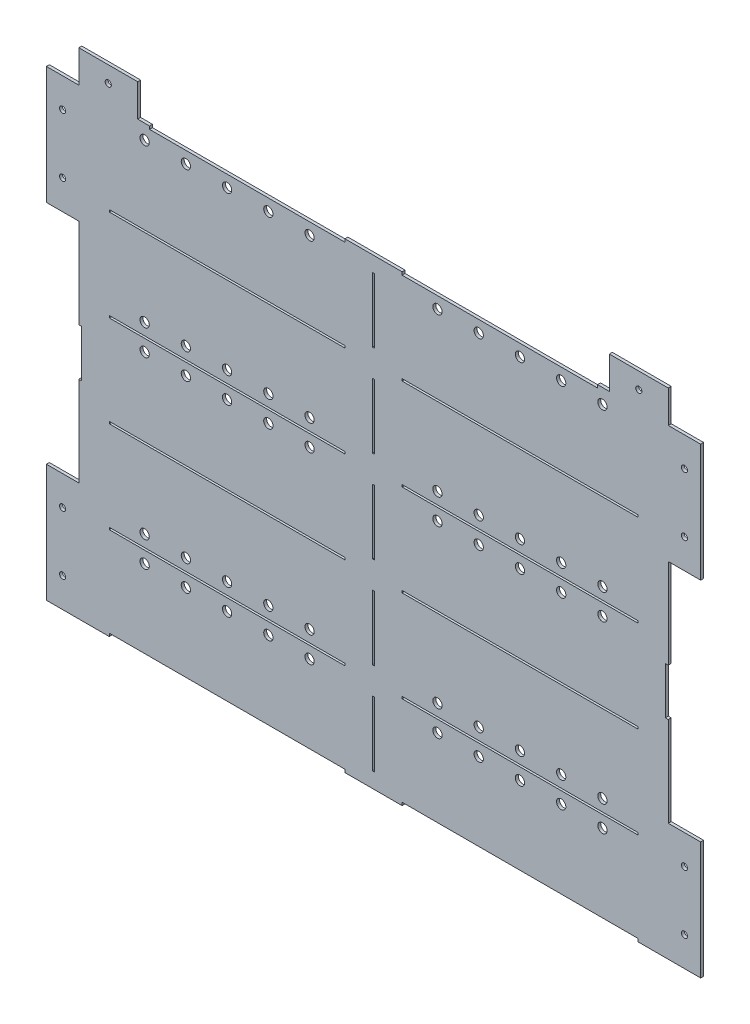
from build123d import *

# Parameters (mm, degrees)
MASTER_SKETCH_W            = 635.3556
MASTER_SKETCH_H            = 498.348
BOSS_EXTRUDE1_DEPTH        = 3.175
SKETCH2_W                  = 34.925
SKETCH2_H                  = 127
BOSS_EXTRUDE2_DEPTH        = 3.175
M6_CLEARANCE_HOLE1_D       = 6.6
MIRROR7_COPY_1_SKETCH_W    = 34.925
MIRROR7_COPY_1_SKETCH_H    = 127
MIRROR7_COPY_1_DEPTH       = 3.175
MIRROR7_COPY_2_D           = 6.6
SKETCH5_W                  = 2.286
SKETCH5_H                  = 69.85
CUT_EXTRUDE1_DEPTH         = 4.175
LPATTERN1_COUNT            = 5
LPATTERN1_PITCH            = 98.8568
SKETCH7_W                  = 254
SKETCH7_H                  = 2.286
CUT_EXTRUDE3_DEPTH         = 4.175
LPATTERN2_COUNT            = 4
LPATTERN2_PITCH            = 98.8568
MIRROR4_COPY_1_SKETCH_W    = 254
MIRROR4_COPY_1_SKETCH_H    = 2.286
MIRROR4_COPY_1_DEPTH       = 4.175
MIRROR4_COPY_2_SKETCH_W    = 254
MIRROR4_COPY_2_SKETCH_H    = 2.286
MIRROR4_COPY_2_DEPTH       = 4.175
MIRROR4_COPY_3_SKETCH_W    = 254
MIRROR4_COPY_3_SKETCH_H    = 2.286
MIRROR4_COPY_3_DEPTH       = 4.175
SKETCH10_W                 = 63.5
SKETCH10_H                 = 34.925
SKETCH10_R                 = 3
BOSS_EXTRUDE3_DEPTH        = 3.175
M6_CLEARANCE_HOLE2_D       = 6.6
SKETCH6_W                  = 254
SKETCH6_H                  = 3.175
SKETCH6_W_2                = 210.6549
CUT_EXTRUDE2_DEPTH         = 4.175
SKETCH15_W                 = 6.35
SKETCH15_H                 = 50.8
CUT_EXTRUDE4_DEPTH         = 4.175
SKETCH16_R                 = 5
CUT_EXTRUDE5_DEPTH         = 4.175
LPATTERN3_COUNT            = 3
LPATTERN3_PITCH            = 44.45
LPATTERN3_COL_COUNT        = 3
LPATTERN3_COL_PITCH        = 44.45
MIRROR9_COPY_1_SKETCH_R    = 5
MIRROR9_COPY_1_DEPTH       = 4.175
MIRROR9_COPY_2_SKETCH_R    = 5
MIRROR9_COPY_2_DEPTH       = 4.175
MIRROR9_COPY_3_SKETCH_R    = 5
MIRROR9_COPY_3_DEPTH       = 4.175
MIRROR9_COPY_4_SKETCH_R    = 5
MIRROR9_COPY_4_DEPTH       = 4.175
MIRROR10_COPY_1_SKETCH_R   = 5
MIRROR10_COPY_1_DEPTH      = 4.175
MIRROR10_COPY_2_SKETCH_R   = 5
MIRROR10_COPY_2_DEPTH      = 4.175
MIRROR10_COPY_3_SKETCH_R   = 5
MIRROR10_COPY_3_DEPTH      = 4.175
MIRROR10_COPY_4_SKETCH_R   = 5
MIRROR10_COPY_4_DEPTH      = 4.175
MIRROR10_COPY_5_SKETCH_R   = 5
MIRROR10_COPY_5_DEPTH      = 4.175
MIRROR10_COPY_6_SKETCH_R   = 5
MIRROR10_COPY_6_DEPTH      = 4.175
MIRROR10_COPY_7_SKETCH_R   = 5
MIRROR10_COPY_7_DEPTH      = 4.175
MIRROR10_COPY_8_SKETCH_R   = 5
MIRROR10_COPY_8_DEPTH      = 4.175
MIRROR10_COPY_9_SKETCH_R   = 5
MIRROR10_COPY_9_DEPTH      = 4.175
LPATTERN4_COUNT            = 2
LPATTERN4_PITCH            = 395.4272
LPATTERN4_COPY_1_SKETCH_R  = 5
LPATTERN4_COPY_1_DEPTH     = 4.175
LPATTERN4_COPY_2_SKETCH_R  = 5
LPATTERN4_COPY_2_DEPTH     = 4.175
LPATTERN4_COPY_3_SKETCH_R  = 5
LPATTERN4_COPY_3_DEPTH     = 4.175
LPATTERN4_COPY_4_SKETCH_R  = 5
LPATTERN4_COPY_4_DEPTH     = 4.175
LPATTERN4_COPY_5_SKETCH_R  = 5
LPATTERN4_COPY_5_DEPTH     = 4.175
LPATTERN4_COPY_6_SKETCH_R  = 5
LPATTERN4_COPY_6_DEPTH     = 4.175
LPATTERN4_COPY_7_SKETCH_R  = 5
LPATTERN4_COPY_7_DEPTH     = 4.175
LPATTERN4_COPY_8_SKETCH_R  = 5
LPATTERN4_COPY_8_DEPTH     = 4.175
LPATTERN4_COPY_9_SKETCH_R  = 5
LPATTERN4_COPY_9_DEPTH     = 4.175
LPATTERN6_COUNT            = 2
LPATTERN6_PITCH            = 197.7136
LPATTERN6_COPY_1_SKETCH_R  = 5
LPATTERN6_COPY_1_DEPTH     = 4.175
LPATTERN6_COPY_2_SKETCH_R  = 5
LPATTERN6_COPY_2_DEPTH     = 4.175
LPATTERN6_COPY_3_SKETCH_R  = 5
LPATTERN6_COPY_3_DEPTH     = 4.175
LPATTERN6_COPY_4_SKETCH_R  = 5
LPATTERN6_COPY_4_DEPTH     = 4.175
LPATTERN6_COPY_5_SKETCH_R  = 5
LPATTERN6_COPY_5_DEPTH     = 4.175
LPATTERN6_COPY_6_SKETCH_R  = 5
LPATTERN6_COPY_6_DEPTH     = 4.175
LPATTERN6_COPY_7_SKETCH_R  = 5
LPATTERN6_COPY_7_DEPTH     = 4.175
LPATTERN6_COPY_8_SKETCH_R  = 5
LPATTERN6_COPY_8_DEPTH     = 4.175
LPATTERN6_COPY_9_SKETCH_R  = 5
LPATTERN6_COPY_9_DEPTH     = 4.175
LPATTERN6_COPY_10_SKETCH_R = 5
LPATTERN6_COPY_10_DEPTH    = 4.175
LPATTERN6_COPY_11_SKETCH_R = 5
LPATTERN6_COPY_11_DEPTH    = 4.175
LPATTERN6_COPY_12_SKETCH_R = 5
LPATTERN6_COPY_12_DEPTH    = 4.175
LPATTERN6_COPY_13_SKETCH_R = 5
LPATTERN6_COPY_13_DEPTH    = 4.175
LPATTERN6_COPY_14_SKETCH_R = 5
LPATTERN6_COPY_14_DEPTH    = 4.175
LPATTERN6_COPY_15_SKETCH_R = 5
LPATTERN6_COPY_15_DEPTH    = 4.175
LPATTERN6_COPY_16_SKETCH_R = 5
LPATTERN6_COPY_16_DEPTH    = 4.175
LPATTERN6_COPY_17_SKETCH_R = 5
LPATTERN6_COPY_17_DEPTH    = 4.175
LPATTERN6_COPY_18_SKETCH_R = 5
LPATTERN6_COPY_18_DEPTH    = 4.175
LPATTERN6_COPY_19_SKETCH_R = 5
LPATTERN6_COPY_19_DEPTH    = 4.175


with BuildPart() as part:
    # Master Sketch → Boss-Extrude1 (new body)
    with BuildSketch(Plane.XY):
        Rectangle(MASTER_SKETCH_W, MASTER_SKETCH_H)
    extrude(amount=BOSS_EXTRUDE1_DEPTH)

    # Sketch2 → Boss-Extrude2 (add)
    with BuildSketch(Plane.XY.offset(3.175)):
        with Locations((-335.1403, -185.674)):
            Rectangle(SKETCH2_W, SKETCH2_H)
    boss_extrude2 = extrude(amount=-BOSS_EXTRUDE2_DEPTH)

    # M6 Clearance Hole1 (through all)
    with Locations(Plane.XY.offset(3.175)):
        with Locations((-335.1403, -217.424), (-335.1403, -153.924)):
            m6_clearance_hole1 = Hole(M6_CLEARANCE_HOLE1_D / 2)

    # Mirror1: Boss-Extrude2, M6 Clearance Hole1 across plane
    add(boss_extrude2.mirror(Plane(origin=(0, 0, 0), x_dir=(0, 0, 1), z_dir=(1, 0, 0))))
    add(m6_clearance_hole1.mirror(Plane(origin=(0, 0, 0), x_dir=(0, 0, 1), z_dir=(1, 0, 0))), mode=Mode.SUBTRACT)

    # Mirror7: Boss-Extrude2, M6 Clearance Hole1 across plane
    add(boss_extrude2.mirror(Plane.ZX))
    add(m6_clearance_hole1.mirror(Plane.ZX), mode=Mode.SUBTRACT)

    # Mirror7 copy 1 sketch → Mirror7 copy 1 (add)
    with BuildSketch(Plane(origin=(0, 0, 3.175), x_dir=(-1, 0, 0), z_dir=(0, 0, 1))):
        with Locations((-335.1403, -185.674)):
            Rectangle(MIRROR7_COPY_1_SKETCH_W, MIRROR7_COPY_1_SKETCH_H)
    extrude(amount=-MIRROR7_COPY_1_DEPTH)

    # Mirror7 copy 2 (through all)
    with Locations(Plane(origin=(0, 0, 3.175), x_dir=(-1, 0, 0), z_dir=(0, 0, 1))):
        with Locations((-335.1403, -217.424), (-335.1403, -153.924)):
            Hole(MIRROR7_COPY_2_D / 2)

    # Sketch5 → Cut-Extrude1 (cut, through all)
    with BuildSketch(Plane.XY.offset(3.175)):
        with Locations((0, 197.7136)):
            Rectangle(SKETCH5_W, SKETCH5_H)
    cut_extrude1 = extrude(amount=-CUT_EXTRUDE1_DEPTH, mode=Mode.SUBTRACT)

    # LPattern1: Cut-Extrude1 ×5
    with Locations(*[(0, -i * LPATTERN1_PITCH, 0) for i in range(1, LPATTERN1_COUNT)]):
        add(cut_extrude1, mode=Mode.SUBTRACT)

    # Sketch7 → Cut-Extrude3 (cut, through all)
    with BuildSketch(Plane.XY.offset(3.175)):
        with Locations((-157.8229, 148.2852)):
            Rectangle(SKETCH7_W, SKETCH7_H)
    cut_extrude3 = extrude(amount=-CUT_EXTRUDE3_DEPTH, mode=Mode.SUBTRACT)

    # LPattern2: Cut-Extrude3 ×4
    with Locations(*[(0, -i * LPATTERN2_PITCH, 0) for i in range(1, LPATTERN2_COUNT)]):
        add(cut_extrude3, mode=Mode.SUBTRACT)

    # Mirror4: Cut-Extrude3 across plane
    add(cut_extrude3.mirror(Plane(origin=(0, 0, 0), x_dir=(0, 0, 1), z_dir=(1, 0, 0))), mode=Mode.SUBTRACT)

    # Mirror4 copy 1 sketch → Mirror4 copy 1 (cut, through all)
    with BuildSketch(Plane(origin=(0, -98.8568, 3.175), x_dir=(-1, 0, 0), z_dir=(0, 0, 1))):
        with Locations((-157.8229, -148.2852)):
            Rectangle(MIRROR4_COPY_1_SKETCH_W, MIRROR4_COPY_1_SKETCH_H)
    extrude(amount=-MIRROR4_COPY_1_DEPTH, mode=Mode.SUBTRACT)

    # Mirror4 copy 2 sketch → Mirror4 copy 2 (cut, through all)
    with BuildSketch(Plane(origin=(0, -197.7136, 3.175), x_dir=(-1, 0, 0), z_dir=(0, 0, 1))):
        with Locations((-157.8229, -148.2852)):
            Rectangle(MIRROR4_COPY_2_SKETCH_W, MIRROR4_COPY_2_SKETCH_H)
    extrude(amount=-MIRROR4_COPY_2_DEPTH, mode=Mode.SUBTRACT)

    # Mirror4 copy 3 sketch → Mirror4 copy 3 (cut, through all)
    with BuildSketch(Plane(origin=(0, -296.5704, 3.175), x_dir=(-1, 0, 0), z_dir=(0, 0, 1))):
        with Locations((-157.8229, -148.2852)):
            Rectangle(MIRROR4_COPY_3_SKETCH_W, MIRROR4_COPY_3_SKETCH_H)
    extrude(amount=-MIRROR4_COPY_3_DEPTH, mode=Mode.SUBTRACT)

    # Sketch10 → Boss-Extrude3 (add)
    with BuildSketch(Plane.XY.offset(3.175)):
        with Locations((-285.9278, 266.6365)):
            Rectangle(SKETCH10_W, SKETCH10_H)
        with Locations((-285.9278, 266.6365)):
            Circle(SKETCH10_R, mode=Mode.SUBTRACT)
    boss_extrude3 = extrude(amount=-BOSS_EXTRUDE3_DEPTH)

    # M6 Clearance Hole2 (through all)
    with Locations(Plane.XY.offset(3.175)):
        with Locations((-285.9278, 266.6365)):
            m6_clearance_hole2 = Hole(M6_CLEARANCE_HOLE2_D / 2)

    # Mirror6: Boss-Extrude3, M6 Clearance Hole2 across plane
    add(boss_extrude3.mirror(Plane(origin=(0, 0, 0), x_dir=(0, 0, 1), z_dir=(1, 0, 0))))
    add(m6_clearance_hole2.mirror(Plane(origin=(0, 0, 0), x_dir=(0, 0, 1), z_dir=(1, 0, 0))), mode=Mode.SUBTRACT)

    # Sketch6 → Cut-Extrude2 (cut, through all)
    with BuildSketch(Plane.XY.offset(3.175)):
        with Locations((-157.8229, -247.5865)):
            Rectangle(SKETCH6_W, SKETCH6_H)
        with Locations((157.8229, -247.5865)):
            Rectangle(SKETCH6_W, SKETCH6_H)
        with Locations((-136.15035, 247.5865)):
            Rectangle(SKETCH6_W_2, SKETCH6_H)
        with Locations((136.15035, 247.5865)):
            Rectangle(SKETCH6_W_2, SKETCH6_H)
    extrude(amount=-CUT_EXTRUDE2_DEPTH, mode=Mode.SUBTRACT)

    # Sketch15 → Cut-Extrude4 (cut, through all)
    with BuildSketch(Plane(origin=(0, 0, 0), x_dir=(-1, 0, 0), z_dir=(0, 0, -1))):
        with Locations((317.6778, 0)):
            Rectangle(SKETCH15_W, SKETCH15_H)
    cut_extrude4 = extrude(amount=-CUT_EXTRUDE4_DEPTH, mode=Mode.SUBTRACT)

    # Mirror8: Cut-Extrude4 across plane
    add(cut_extrude4.mirror(Plane(origin=(0, 0, 0), x_dir=(0, 0, 1), z_dir=(1, 0, 0))), mode=Mode.SUBTRACT)

    # Sketch16 → Cut-Extrude5 (cut, through all)
    with BuildSketch(Plane(origin=(0, 0, 0), x_dir=(-1, 0, 0), z_dir=(0, 0, -1))):
        with Locations((-157.8229, -162.1282)):
            Circle(SKETCH16_R)
    cut_extrude5 = extrude(amount=-CUT_EXTRUDE5_DEPTH, mode=Mode.SUBTRACT)

    # LPattern3: Cut-Extrude5 ×3
    with Locations(*[(i * LPATTERN3_PITCH, 0, 0) for i in range(1, LPATTERN3_COUNT)]):
        add(cut_extrude5, mode=Mode.SUBTRACT)

    # LPattern3 col: Cut-Extrude5 ×3
    with Locations(*[(-i * LPATTERN3_COL_PITCH, 0, 0) for i in range(1, LPATTERN3_COL_COUNT)]):
        add(cut_extrude5, mode=Mode.SUBTRACT)

    # Mirror9: Cut-Extrude5 across plane
    add(cut_extrude5.mirror(Plane(origin=(0, 0, 0), x_dir=(0, 0, 1), z_dir=(1, 0, 0))), mode=Mode.SUBTRACT)

    # Mirror9 copy 1 sketch → Mirror9 copy 1 (cut, through all)
    with BuildSketch(Plane(origin=(-44.45, 0, 0), x_dir=(1, 0, 0), z_dir=(0, 0, -1))):
        with Locations((-157.8229, 162.1282)):
            Circle(MIRROR9_COPY_1_SKETCH_R)
    extrude(amount=-MIRROR9_COPY_1_DEPTH, mode=Mode.SUBTRACT)

    # Mirror9 copy 2 sketch → Mirror9 copy 2 (cut, through all)
    with BuildSketch(Plane(origin=(-88.9, 0, 0), x_dir=(1, 0, 0), z_dir=(0, 0, -1))):
        with Locations((-157.8229, 162.1282)):
            Circle(MIRROR9_COPY_2_SKETCH_R)
    extrude(amount=-MIRROR9_COPY_2_DEPTH, mode=Mode.SUBTRACT)

    # Mirror9 copy 3 sketch → Mirror9 copy 3 (cut, through all)
    with BuildSketch(Plane(origin=(44.45, 0, 0), x_dir=(1, 0, 0), z_dir=(0, 0, -1))):
        with Locations((-157.8229, 162.1282)):
            Circle(MIRROR9_COPY_3_SKETCH_R)
    extrude(amount=-MIRROR9_COPY_3_DEPTH, mode=Mode.SUBTRACT)

    # Mirror9 copy 4 sketch → Mirror9 copy 4 (cut, through all)
    with BuildSketch(Plane(origin=(88.9, 0, 0), x_dir=(1, 0, 0), z_dir=(0, 0, -1))):
        with Locations((-157.8229, 162.1282)):
            Circle(MIRROR9_COPY_4_SKETCH_R)
    extrude(amount=-MIRROR9_COPY_4_DEPTH, mode=Mode.SUBTRACT)

    # Mirror10: Cut-Extrude5 across plane
    add(cut_extrude5.mirror(Plane.ZX.offset(-148.2852)), mode=Mode.SUBTRACT)

    # Mirror10 copy 1 sketch → Mirror10 copy 1 (cut, through all)
    with BuildSketch(Plane(origin=(0, -296.5704, 0), x_dir=(1, 0, 0), z_dir=(0, 0, -1))):
        with Locations((-157.8229, -162.1282)):
            Circle(MIRROR10_COPY_1_SKETCH_R)
    extrude(amount=-MIRROR10_COPY_1_DEPTH, mode=Mode.SUBTRACT)

    # Mirror10 copy 2 sketch → Mirror10 copy 2 (cut, through all)
    with BuildSketch(Plane(origin=(-44.45, -296.5704, 0), x_dir=(1, 0, 0), z_dir=(0, 0, -1))):
        with Locations((-157.8229, -162.1282)):
            Circle(MIRROR10_COPY_2_SKETCH_R)
    extrude(amount=-MIRROR10_COPY_2_DEPTH, mode=Mode.SUBTRACT)

    # Mirror10 copy 3 sketch → Mirror10 copy 3 (cut, through all)
    with BuildSketch(Plane(origin=(-88.9, -296.5704, 0), x_dir=(1, 0, 0), z_dir=(0, 0, -1))):
        with Locations((-157.8229, -162.1282)):
            Circle(MIRROR10_COPY_3_SKETCH_R)
    extrude(amount=-MIRROR10_COPY_3_DEPTH, mode=Mode.SUBTRACT)

    # Mirror10 copy 4 sketch → Mirror10 copy 4 (cut, through all)
    with BuildSketch(Plane(origin=(44.45, -296.5704, 0), x_dir=(1, 0, 0), z_dir=(0, 0, -1))):
        with Locations((-157.8229, -162.1282)):
            Circle(MIRROR10_COPY_4_SKETCH_R)
    extrude(amount=-MIRROR10_COPY_4_DEPTH, mode=Mode.SUBTRACT)

    # Mirror10 copy 5 sketch → Mirror10 copy 5 (cut, through all)
    with BuildSketch(Plane(origin=(88.9, -296.5704, 0), x_dir=(1, 0, 0), z_dir=(0, 0, -1))):
        with Locations((-157.8229, -162.1282)):
            Circle(MIRROR10_COPY_5_SKETCH_R)
    extrude(amount=-MIRROR10_COPY_5_DEPTH, mode=Mode.SUBTRACT)

    # Mirror10 copy 6 sketch → Mirror10 copy 6 (cut, through all)
    with BuildSketch(Plane(origin=(44.45, -296.5704, 0), x_dir=(-1, 0, 0), z_dir=(0, 0, -1))):
        with Locations((-157.8229, 162.1282)):
            Circle(MIRROR10_COPY_6_SKETCH_R)
    extrude(amount=-MIRROR10_COPY_6_DEPTH, mode=Mode.SUBTRACT)

    # Mirror10 copy 7 sketch → Mirror10 copy 7 (cut, through all)
    with BuildSketch(Plane(origin=(88.9, -296.5704, 0), x_dir=(-1, 0, 0), z_dir=(0, 0, -1))):
        with Locations((-157.8229, 162.1282)):
            Circle(MIRROR10_COPY_7_SKETCH_R)
    extrude(amount=-MIRROR10_COPY_7_DEPTH, mode=Mode.SUBTRACT)

    # Mirror10 copy 8 sketch → Mirror10 copy 8 (cut, through all)
    with BuildSketch(Plane(origin=(-44.45, -296.5704, 0), x_dir=(-1, 0, 0), z_dir=(0, 0, -1))):
        with Locations((-157.8229, 162.1282)):
            Circle(MIRROR10_COPY_8_SKETCH_R)
    extrude(amount=-MIRROR10_COPY_8_DEPTH, mode=Mode.SUBTRACT)

    # Mirror10 copy 9 sketch → Mirror10 copy 9 (cut, through all)
    with BuildSketch(Plane(origin=(-88.9, -296.5704, 0), x_dir=(-1, 0, 0), z_dir=(0, 0, -1))):
        with Locations((-157.8229, 162.1282)):
            Circle(MIRROR10_COPY_9_SKETCH_R)
    extrude(amount=-MIRROR10_COPY_9_DEPTH, mode=Mode.SUBTRACT)

    # LPattern4: Cut-Extrude5 ×2
    with Locations(*[(0, i * LPATTERN4_PITCH, 0) for i in range(1, LPATTERN4_COUNT)]):
        add(cut_extrude5, mode=Mode.SUBTRACT)

    # LPattern4 copy 1 sketch → LPattern4 copy 1 (cut, through all)
    with BuildSketch(Plane(origin=(44.45, 395.4272, 0), x_dir=(-1, 0, 0), z_dir=(0, 0, -1))):
        with Locations((-157.8229, -162.1282)):
            Circle(LPATTERN4_COPY_1_SKETCH_R)
    extrude(amount=-LPATTERN4_COPY_1_DEPTH, mode=Mode.SUBTRACT)

    # LPattern4 copy 2 sketch → LPattern4 copy 2 (cut, through all)
    with BuildSketch(Plane(origin=(88.9, 395.4272, 0), x_dir=(-1, 0, 0), z_dir=(0, 0, -1))):
        with Locations((-157.8229, -162.1282)):
            Circle(LPATTERN4_COPY_2_SKETCH_R)
    extrude(amount=-LPATTERN4_COPY_2_DEPTH, mode=Mode.SUBTRACT)

    # LPattern4 copy 3 sketch → LPattern4 copy 3 (cut, through all)
    with BuildSketch(Plane(origin=(-44.45, 395.4272, 0), x_dir=(-1, 0, 0), z_dir=(0, 0, -1))):
        with Locations((-157.8229, -162.1282)):
            Circle(LPATTERN4_COPY_3_SKETCH_R)
    extrude(amount=-LPATTERN4_COPY_3_DEPTH, mode=Mode.SUBTRACT)

    # LPattern4 copy 4 sketch → LPattern4 copy 4 (cut, through all)
    with BuildSketch(Plane(origin=(-88.9, 395.4272, 0), x_dir=(-1, 0, 0), z_dir=(0, 0, -1))):
        with Locations((-157.8229, -162.1282)):
            Circle(LPATTERN4_COPY_4_SKETCH_R)
    extrude(amount=-LPATTERN4_COPY_4_DEPTH, mode=Mode.SUBTRACT)

    # LPattern4 copy 5 sketch → LPattern4 copy 5 (cut, through all)
    with BuildSketch(Plane(origin=(0, 395.4272, 0), x_dir=(1, 0, 0), z_dir=(0, 0, -1))):
        with Locations((-157.8229, 162.1282)):
            Circle(LPATTERN4_COPY_5_SKETCH_R)
    extrude(amount=-LPATTERN4_COPY_5_DEPTH, mode=Mode.SUBTRACT)

    # LPattern4 copy 6 sketch → LPattern4 copy 6 (cut, through all)
    with BuildSketch(Plane(origin=(-44.45, 395.4272, 0), x_dir=(1, 0, 0), z_dir=(0, 0, -1))):
        with Locations((-157.8229, 162.1282)):
            Circle(LPATTERN4_COPY_6_SKETCH_R)
    extrude(amount=-LPATTERN4_COPY_6_DEPTH, mode=Mode.SUBTRACT)

    # LPattern4 copy 7 sketch → LPattern4 copy 7 (cut, through all)
    with BuildSketch(Plane(origin=(-88.9, 395.4272, 0), x_dir=(1, 0, 0), z_dir=(0, 0, -1))):
        with Locations((-157.8229, 162.1282)):
            Circle(LPATTERN4_COPY_7_SKETCH_R)
    extrude(amount=-LPATTERN4_COPY_7_DEPTH, mode=Mode.SUBTRACT)

    # LPattern4 copy 8 sketch → LPattern4 copy 8 (cut, through all)
    with BuildSketch(Plane(origin=(44.45, 395.4272, 0), x_dir=(1, 0, 0), z_dir=(0, 0, -1))):
        with Locations((-157.8229, 162.1282)):
            Circle(LPATTERN4_COPY_8_SKETCH_R)
    extrude(amount=-LPATTERN4_COPY_8_DEPTH, mode=Mode.SUBTRACT)

    # LPattern4 copy 9 sketch → LPattern4 copy 9 (cut, through all)
    with BuildSketch(Plane(origin=(88.9, 395.4272, 0), x_dir=(1, 0, 0), z_dir=(0, 0, -1))):
        with Locations((-157.8229, 162.1282)):
            Circle(LPATTERN4_COPY_9_SKETCH_R)
    extrude(amount=-LPATTERN4_COPY_9_DEPTH, mode=Mode.SUBTRACT)

    # LPattern6: Cut-Extrude5 ×2
    with Locations(*[(0, i * LPATTERN6_PITCH, 0) for i in range(1, LPATTERN6_COUNT)]):
        add(cut_extrude5, mode=Mode.SUBTRACT)

    # LPattern6 copy 1 sketch → LPattern6 copy 1 (cut, through all)
    with BuildSketch(Plane(origin=(0, -98.8568, 0), x_dir=(-1, 0, 0), z_dir=(0, 0, -1))):
        with Locations((-157.8229, 162.1282)):
            Circle(LPATTERN6_COPY_1_SKETCH_R)
    extrude(amount=-LPATTERN6_COPY_1_DEPTH, mode=Mode.SUBTRACT)

    # LPattern6 copy 2 sketch → LPattern6 copy 2 (cut, through all)
    with BuildSketch(Plane(origin=(0, -98.8568, 0), x_dir=(1, 0, 0), z_dir=(0, 0, -1))):
        with Locations((-157.8229, -162.1282)):
            Circle(LPATTERN6_COPY_2_SKETCH_R)
    extrude(amount=-LPATTERN6_COPY_2_DEPTH, mode=Mode.SUBTRACT)

    # LPattern6 copy 3 sketch → LPattern6 copy 3 (cut, through all)
    with BuildSketch(Plane(origin=(-44.45, -98.8568, 0), x_dir=(1, 0, 0), z_dir=(0, 0, -1))):
        with Locations((-157.8229, -162.1282)):
            Circle(LPATTERN6_COPY_3_SKETCH_R)
    extrude(amount=-LPATTERN6_COPY_3_DEPTH, mode=Mode.SUBTRACT)

    # LPattern6 copy 4 sketch → LPattern6 copy 4 (cut, through all)
    with BuildSketch(Plane(origin=(-88.9, -98.8568, 0), x_dir=(1, 0, 0), z_dir=(0, 0, -1))):
        with Locations((-157.8229, -162.1282)):
            Circle(LPATTERN6_COPY_4_SKETCH_R)
    extrude(amount=-LPATTERN6_COPY_4_DEPTH, mode=Mode.SUBTRACT)

    # LPattern6 copy 5 sketch → LPattern6 copy 5 (cut, through all)
    with BuildSketch(Plane(origin=(44.45, -98.8568, 0), x_dir=(1, 0, 0), z_dir=(0, 0, -1))):
        with Locations((-157.8229, -162.1282)):
            Circle(LPATTERN6_COPY_5_SKETCH_R)
    extrude(amount=-LPATTERN6_COPY_5_DEPTH, mode=Mode.SUBTRACT)

    # LPattern6 copy 6 sketch → LPattern6 copy 6 (cut, through all)
    with BuildSketch(Plane(origin=(88.9, -98.8568, 0), x_dir=(1, 0, 0), z_dir=(0, 0, -1))):
        with Locations((-157.8229, -162.1282)):
            Circle(LPATTERN6_COPY_6_SKETCH_R)
    extrude(amount=-LPATTERN6_COPY_6_DEPTH, mode=Mode.SUBTRACT)

    # LPattern6 copy 7 sketch → LPattern6 copy 7 (cut, through all)
    with BuildSketch(Plane(origin=(44.45, -98.8568, 0), x_dir=(-1, 0, 0), z_dir=(0, 0, -1))):
        with Locations((-157.8229, 162.1282)):
            Circle(LPATTERN6_COPY_7_SKETCH_R)
    extrude(amount=-LPATTERN6_COPY_7_DEPTH, mode=Mode.SUBTRACT)

    # LPattern6 copy 8 sketch → LPattern6 copy 8 (cut, through all)
    with BuildSketch(Plane(origin=(88.9, -98.8568, 0), x_dir=(-1, 0, 0), z_dir=(0, 0, -1))):
        with Locations((-157.8229, 162.1282)):
            Circle(LPATTERN6_COPY_8_SKETCH_R)
    extrude(amount=-LPATTERN6_COPY_8_DEPTH, mode=Mode.SUBTRACT)

    # LPattern6 copy 9 sketch → LPattern6 copy 9 (cut, through all)
    with BuildSketch(Plane(origin=(-44.45, -98.8568, 0), x_dir=(-1, 0, 0), z_dir=(0, 0, -1))):
        with Locations((-157.8229, 162.1282)):
            Circle(LPATTERN6_COPY_9_SKETCH_R)
    extrude(amount=-LPATTERN6_COPY_9_DEPTH, mode=Mode.SUBTRACT)

    # LPattern6 copy 10 sketch → LPattern6 copy 10 (cut, through all)
    with BuildSketch(Plane(origin=(-88.9, -98.8568, 0), x_dir=(-1, 0, 0), z_dir=(0, 0, -1))):
        with Locations((-157.8229, 162.1282)):
            Circle(LPATTERN6_COPY_10_SKETCH_R)
    extrude(amount=-LPATTERN6_COPY_10_DEPTH, mode=Mode.SUBTRACT)

    # LPattern6 copy 11 sketch → LPattern6 copy 11 (cut, through all)
    with BuildSketch(Plane(origin=(44.45, 197.7136, 0), x_dir=(-1, 0, 0), z_dir=(0, 0, -1))):
        with Locations((-157.8229, -162.1282)):
            Circle(LPATTERN6_COPY_11_SKETCH_R)
    extrude(amount=-LPATTERN6_COPY_11_DEPTH, mode=Mode.SUBTRACT)

    # LPattern6 copy 12 sketch → LPattern6 copy 12 (cut, through all)
    with BuildSketch(Plane(origin=(88.9, 197.7136, 0), x_dir=(-1, 0, 0), z_dir=(0, 0, -1))):
        with Locations((-157.8229, -162.1282)):
            Circle(LPATTERN6_COPY_12_SKETCH_R)
    extrude(amount=-LPATTERN6_COPY_12_DEPTH, mode=Mode.SUBTRACT)

    # LPattern6 copy 13 sketch → LPattern6 copy 13 (cut, through all)
    with BuildSketch(Plane(origin=(-44.45, 197.7136, 0), x_dir=(-1, 0, 0), z_dir=(0, 0, -1))):
        with Locations((-157.8229, -162.1282)):
            Circle(LPATTERN6_COPY_13_SKETCH_R)
    extrude(amount=-LPATTERN6_COPY_13_DEPTH, mode=Mode.SUBTRACT)

    # LPattern6 copy 14 sketch → LPattern6 copy 14 (cut, through all)
    with BuildSketch(Plane(origin=(-88.9, 197.7136, 0), x_dir=(-1, 0, 0), z_dir=(0, 0, -1))):
        with Locations((-157.8229, -162.1282)):
            Circle(LPATTERN6_COPY_14_SKETCH_R)
    extrude(amount=-LPATTERN6_COPY_14_DEPTH, mode=Mode.SUBTRACT)

    # LPattern6 copy 15 sketch → LPattern6 copy 15 (cut, through all)
    with BuildSketch(Plane(origin=(0, 197.7136, 0), x_dir=(1, 0, 0), z_dir=(0, 0, -1))):
        with Locations((-157.8229, 162.1282)):
            Circle(LPATTERN6_COPY_15_SKETCH_R)
    extrude(amount=-LPATTERN6_COPY_15_DEPTH, mode=Mode.SUBTRACT)

    # LPattern6 copy 16 sketch → LPattern6 copy 16 (cut, through all)
    with BuildSketch(Plane(origin=(-44.45, 197.7136, 0), x_dir=(1, 0, 0), z_dir=(0, 0, -1))):
        with Locations((-157.8229, 162.1282)):
            Circle(LPATTERN6_COPY_16_SKETCH_R)
    extrude(amount=-LPATTERN6_COPY_16_DEPTH, mode=Mode.SUBTRACT)

    # LPattern6 copy 17 sketch → LPattern6 copy 17 (cut, through all)
    with BuildSketch(Plane(origin=(-88.9, 197.7136, 0), x_dir=(1, 0, 0), z_dir=(0, 0, -1))):
        with Locations((-157.8229, 162.1282)):
            Circle(LPATTERN6_COPY_17_SKETCH_R)
    extrude(amount=-LPATTERN6_COPY_17_DEPTH, mode=Mode.SUBTRACT)

    # LPattern6 copy 18 sketch → LPattern6 copy 18 (cut, through all)
    with BuildSketch(Plane(origin=(44.45, 197.7136, 0), x_dir=(1, 0, 0), z_dir=(0, 0, -1))):
        with Locations((-157.8229, 162.1282)):
            Circle(LPATTERN6_COPY_18_SKETCH_R)
    extrude(amount=-LPATTERN6_COPY_18_DEPTH, mode=Mode.SUBTRACT)

    # LPattern6 copy 19 sketch → LPattern6 copy 19 (cut, through all)
    with BuildSketch(Plane(origin=(88.9, 197.7136, 0), x_dir=(1, 0, 0), z_dir=(0, 0, -1))):
        with Locations((-157.8229, 162.1282)):
            Circle(LPATTERN6_COPY_19_SKETCH_R)
    extrude(amount=-LPATTERN6_COPY_19_DEPTH, mode=Mode.SUBTRACT)


solid = part.part
